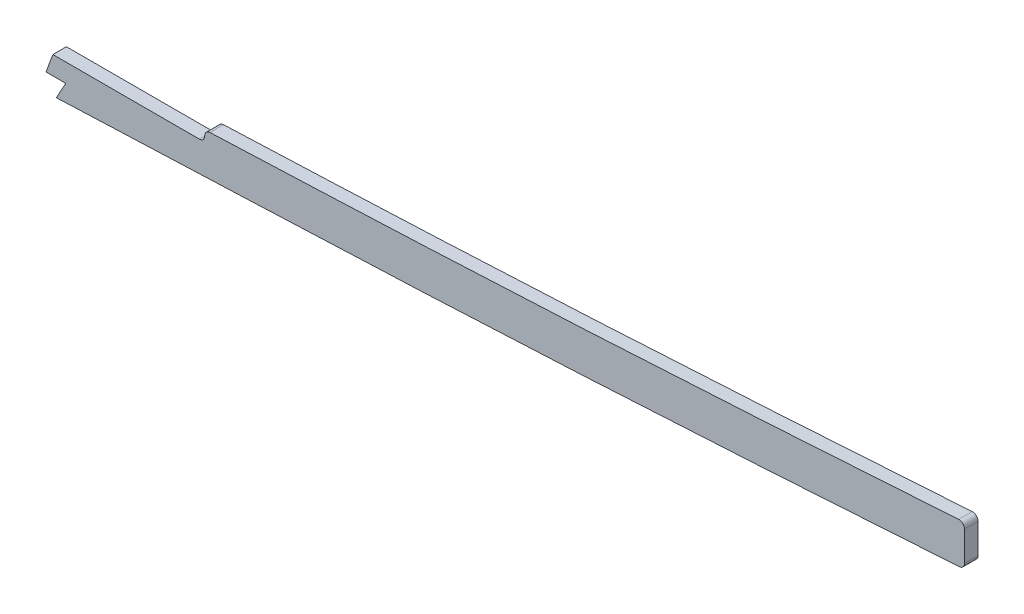
from build123d import *

# Parameters (mm, degrees)
BOSS_EXTRUDE1_DEPTH = 3.175
CUT_EXTRUDE1_DEPTH  = 7.3500001
FILLET1_R           = 2.54
CUT_EXTRUDE2_DEPTH  = 7.62


with BuildPart() as part:
    # Sketch1 → Boss-Extrude1 (new body, symmetric)
    with BuildSketch(Plane.XY):
        with BuildLine():
            Line((499.61002795, -53.470702797), (1046.28548189, -53.470702797))
            add(Edge.make_bspline(
                [(2669.54, -9.569049356), (2615.393603553, -13.17073937), (2561.080658619, -16.536108081), (2506.205230446, -19.758621957), (2430.209106802, -23.505211705), (2354.212983157, -26.631486423), (2332.570330468, -27.480988169), (2156.268639429, -34.377768543), (1979.966947376, -41.628631248), (1824.114277635, -52.771265877), (1636.928606778, -53.579569849), (1449.742935921, -53.454024613), (1418.006730935, -53.470702797), (1324.899336146, -53.470702797), (1231.791940344, -53.470702797), (1170.441269319, -53.470702797), (1108.784075813, -53.470702797), (1047.126882346, -53.470702797), (1046.846414188, -53.470702797), (1046.565947184, -53.470702797), (1046.28548189, -53.470702797)],
                knots=[103.698913506, 103.698913506, 103.698913506, 103.698913506, 103.698913506, 103.698913506, 130.927896619, 130.927896619, 130.927896619, 141.337054719, 141.337054719, 141.337054719, 218.101815019, 218.101815019, 218.101815019, 233.772059419, 233.772059419, 233.772059419, 264.077723219, 264.077723219, 264.077723219, 264.2162088, 264.2162088, 264.2162088, 264.2162088, 264.2162088, 264.2162088], degree=5))
            Line((2669.54, -9.569049356), (2669.54, 9.5231025))
            add(Edge.make_bspline(
                [(2669.54, 9.5231025), (2667.126494524, 9.36235515), (2659.861586685, 8.880281494), (2635.666282302, 7.292469146), (2596.857665529, 4.826056853), (2545.729743039, 1.758344093), (2494.405305707, -1.098555235), (2451.533022267, -3.266573297), (2417.198316756, -4.86708361), (2391.457076919, -6.003589235), (2365.634736307, -7.086854581), (2339.546284672, -8.137729944), (2313.466132974, -9.165138371), (2287.612375486, -10.179478215), (2261.763347437, -11.201032297), (2227.285329715, -12.583842557), (2184.175569393, -14.36607236), (2132.429066114, -16.607427868), (2063.4255234, -19.708920485), (1977.174907635, -23.700543313), (1873.732451432, -28.149389221), (1770.37461881, -31.657468649), (1667.085687813, -33.793117556), (1581.011094491, -34.383188831), (1512.07397126, -34.4278026), (1443.061513477, -34.409510402), (1356.800927879, -34.424432812), (1218.794626954, -34.418464788), (1115.289022786, -34.420702797), (1046.28548189, -34.420702797)],
                knots=[103.571582669, 103.571582669, 103.571582669, 103.571582669, 104.300777207, 105.766098403, 110.877392287, 115.98868617, 121.099980054, 126.211273938, 128.76692088, 131.322567822, 133.878214764, 136.433861706, 138.989508647, 141.545155589, 144.100802531, 146.656449473, 151.767743357, 156.879037241, 161.990331124, 172.212918892, 182.43550666, 192.658094427, 202.880682195, 213.103269962, 218.214563846, 223.32585773, 233.548445497, 243.771033265, 264.2162088, 264.2162088, 264.2162088, 264.2162088], degree=3))
            Line((1046.28548189, -34.420702797), (499.61002795, -34.420702797))
            add(Edge.make_bspline(
                [(499.61002795, -34.420702797), (488.614737518, -34.420702797), (472.236395365, -34.420702798), (449.940231846, -34.420702794), (427.771305695, -34.42070281), (405.874681663, -34.420702712), (384.584909128, -34.420702942), (368.900229326, -34.420702244), (353.376568613, -34.420704862), (332.608466435, -34.420689186), (306.287754853, -34.420570006), (274.023487704, -34.420538256), (252.271015965, -34.420709741), (241.425150134, -34.420702761)],
                knots=[19.90682951, 19.90682951, 19.90682951, 19.90682951, 23.220120017, 24.876765271, 26.533410525, 29.846701033, 31.503346286, 33.15999154, 34.816636794, 36.473282048, 39.786572556, 43.099863063, 46.413153571, 46.413153571, 46.413153571, 46.413153571], degree=3))
            add(Edge.make_bspline(
                [(241.425150134, -34.420702761), (239.394928853, -34.420701455), (235.322322927, -34.420495867), (227.274423443, -34.398702533), (217.319360062, -34.297466855), (205.530690077, -33.976385563), (189.963341914, -33.212641271), (170.696984653, -31.543495194), (147.533261232, -28.314398128), (125.482753206, -24.202109872), (109.358914834, -20.622537553), (100.964116069, -18.612521054), (99.06, -18.149327722)],
                knots=[0, 0, 0, 0, 0.622088422, 1.244176844, 2.488353689, 3.732530533, 4.976707377, 7.465061066, 9.953414755, 12.441768444, 14.55823542, 15.180323842, 15.180323842, 15.180323842, 15.180323842], degree=3))
            Line((99.06, -18.149327722), (99.06, -37.741485304))
            add(Edge.make_bspline(
                [(241.425137875, -53.470702761), (224.286916993, -53.470691732), (207.149474967, -53.467315374), (190.203897513, -52.686577078), (161.734965878, -49.987457476), (133.266034188, -45.175583375), (121.749620566, -42.910592695), (110.349390726, -40.420274627), (99.06, -37.741485304)],
                knots=[0, 0, 0, 0, 0, 0, 8.71381608, 8.71381608, 8.71381608, 14.701907176, 14.701907176, 14.701907176, 14.701907176, 14.701907176, 14.701907176], degree=5))
            add(Edge.make_bspline(
                [(499.61002795, -53.470702797), (492.136820835, -53.470702797), (484.754348064, -53.470702797), (477.443025859, -53.470702797), (448.516583145, -53.470702797), (419.590140517, -53.470702797), (398.368118521, -53.470702797), (355.647540186, -53.470702797), (312.926961851, -53.470702797), (289.235090436, -53.470293029), (265.364963651, -53.470705034), (241.4948369, -53.470702789), (241.471603891, -53.470702785), (241.448370882, -53.470702776), (241.425137875, -53.470702761)],
                knots=[19.90682951, 19.90682951, 19.90682951, 19.90682951, 19.90682951, 19.90682951, 23.637897311, 23.637897311, 23.637897311, 34.276545571, 34.276545571, 34.276545571, 46.401340901, 46.401340901, 46.401340901, 46.413153571, 46.413153571, 46.413153571, 46.413153571, 46.413153571, 46.413153571], degree=5))
        make_face()
    extrude(amount=BOSS_EXTRUDE1_DEPTH, both=True)

    # Sketch2 → Cut-Extrude1 (cut, through all)
    with BuildSketch(Plane.XY.offset(3.175)):
        with BuildLine():
            add(Edge.make_bspline(
                [(2312.9875, -9.183260037), (2304.505441691, -9.516700376), (2287.441020622, -10.186250162), (2261.763347437, -11.201032297), (2228.230552004, -12.545932515), (2203.310445107, -13.575047161), (2187.00995947, -14.263260037)],
                knots=[139.04033329, 139.04033329, 139.04033329, 139.04033329, 141.545155589, 144.100802531, 146.656449473, 151.487488909, 151.487488909, 151.487488909, 151.487488909], degree=3))
            Line((2187.00995947, -14.263260037), (2312.9875, -14.263260037))
            Line((2312.9875, -14.263260037), (2312.9875, -9.183260037))
        make_face()
    extrude(amount=-CUT_EXTRUDE1_DEPTH, mode=Mode.SUBTRACT)

    # Fillet1
    fillet1_edges = [part.edges().sort_by_distance(p)[0] for p in [
        (2669.54, -9.569049356, -1.5875),
        (2669.54, 9.5231025, -1.5875),
        (99.06, -37.741485304, -1.5875),
        (99.06, -18.149327722, -1.5875),
        (2312.9875, -9.183260037, 1.5875),
        (2312.9875, -14.263260037, 0),
    ]]
    fillet(fillet1_edges, radius=FILLET1_R)

    # Sketch3 → Cut-Extrude2 (cut)
    with BuildSketch(Plane.XY.offset(3.175)):
        Polygon((2241.72424439, -14.263260032), (2238.495432608, -22.960040401), (2247.777444945, -22.960040401), (2243.337690155, -31.006850231), (2243.337690155, -46.204944132), (-44.767190061, -591.123475599), (-136.430103916, 149.230828615), (2241.72424439, 0), align=None)
    extrude(amount=-CUT_EXTRUDE2_DEPTH, mode=Mode.SUBTRACT)


solid = part.part
